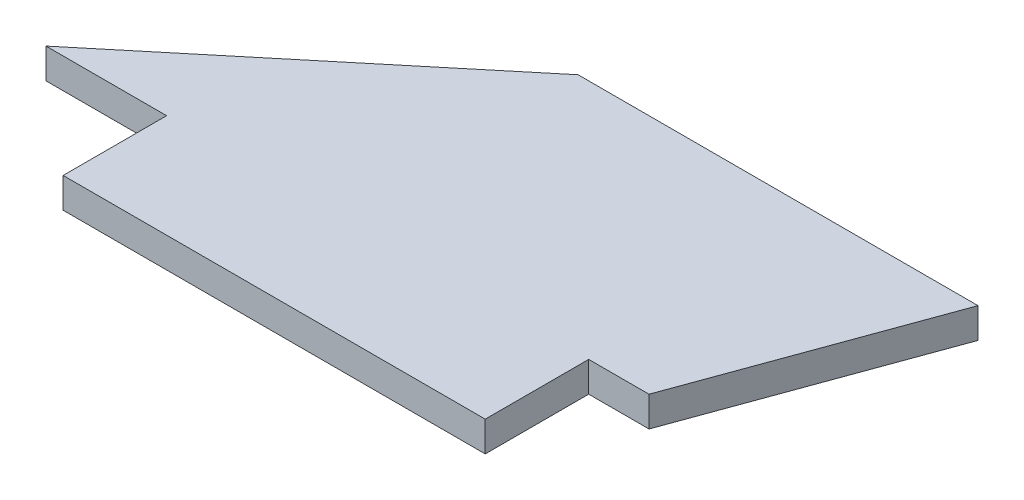
from build123d import *

# Parameters (mm, degrees)
BOSS_EXTRUDE1_DEPTH = 2.5


with BuildPart() as part:
    # Sketch1 → Boss-Extrude1 (new body, symmetric)
    with BuildSketch(Plane(origin=(0, 0, 0), x_dir=(1, 0, 0), z_dir=(0, 1, 0))):
        Polygon((0, 0), (20, 0), (20, -17.16), (90, -17.16), (90, 0), (100, 0), (114.558809371, 40), (48.238809371, 40), align=None)
    extrude(amount=BOSS_EXTRUDE1_DEPTH, both=True)


solid = part.part
